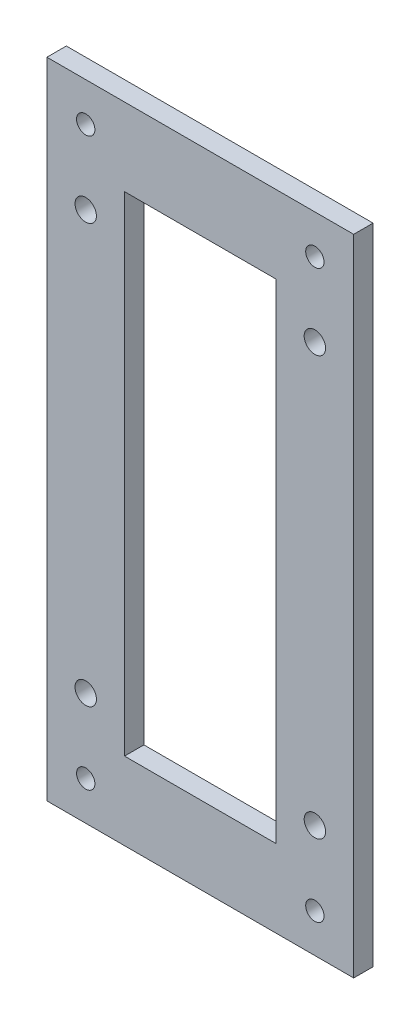
from build123d import *

# Parameters (mm, degrees)
SKETCH1_W           = 100.4
SKETCH1_H           = 210.8
SKETCH1_W_2         = 49.6
SKETCH1_H_2         = 160
BOSS_EXTRUDE1_DEPTH = 6.35
SKETCH2_R           = 3
CUT_EXTRUDE1_DEPTH  = 6.35
SKETCH3_R           = 3.5
CUT_EXTRUDE2_DEPTH  = 10


with BuildPart() as part:
    # Sketch1 → Boss-Extrude1 (new body)
    with BuildSketch(Plane.XY):
        with Locations((50.2, 105.4)):
            Rectangle(SKETCH1_W, SKETCH1_H)
        with Locations((50.2, 105.4)):
            Rectangle(SKETCH1_W_2, SKETCH1_H_2, mode=Mode.SUBTRACT)
    extrude(amount=BOSS_EXTRUDE1_DEPTH)

    # Sketch2 → Cut-Extrude1 (cut)
    with BuildSketch(Plane.XY.offset(6.35)):
        with Locations((12.70273435, 198.1)):
            Circle(SKETCH2_R)
        with Locations((87.69726565, 198.1)):
            Circle(SKETCH2_R)
        with Locations((87.69726565, 12.7)):
            Circle(SKETCH2_R)
        with Locations((12.70273435, 12.7)):
            Circle(SKETCH2_R)
    extrude(amount=-CUT_EXTRUDE1_DEPTH, mode=Mode.SUBTRACT)

    # Sketch3 → Cut-Extrude2 (cut)
    with BuildSketch(Plane.XY.offset(6.35)):
        with Locations((12.7, 173.9)):
            Circle(SKETCH3_R)
        with Locations((87.7, 173.9)):
            Circle(SKETCH3_R)
        with Locations((87.7, 36.9)):
            Circle(SKETCH3_R)
        with Locations((12.7, 36.9)):
            Circle(SKETCH3_R)
    extrude(amount=-CUT_EXTRUDE2_DEPTH, mode=Mode.SUBTRACT)


solid = part.part
